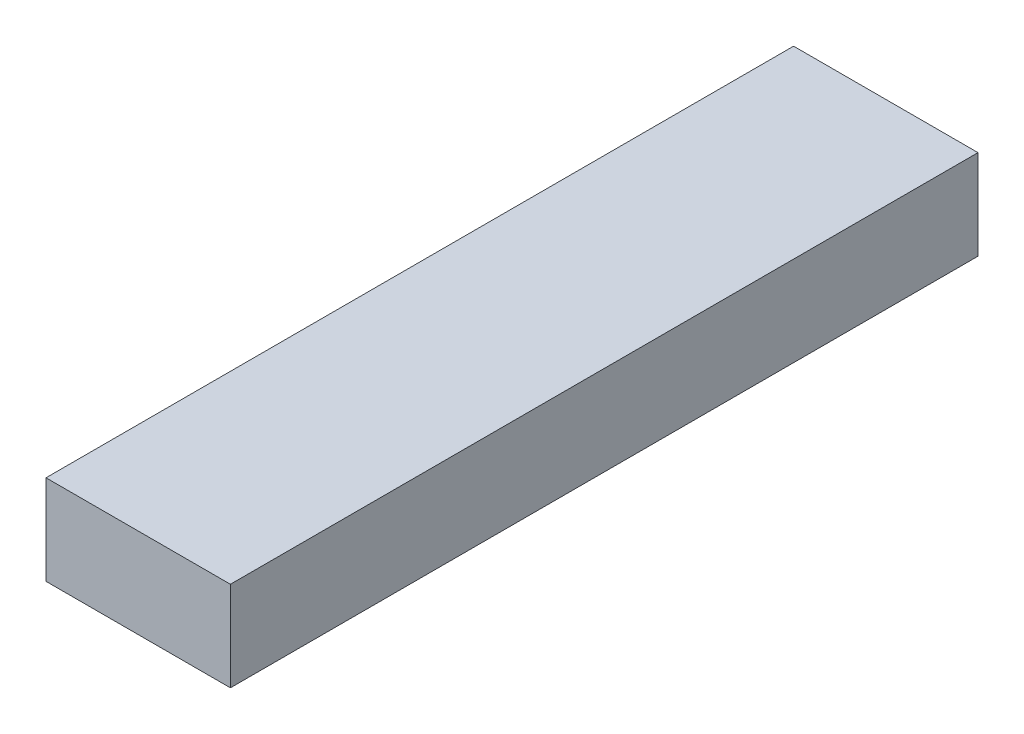
from build123d import *

# Parameters (mm, degrees)
SKETCH1_W           = 3.7
SKETCH1_H           = 1.8
BOSS_EXTRUDE1_DEPTH = 15


with BuildPart() as part:
    # Sketch1 → Boss-Extrude1 (new body)
    with BuildSketch(Plane.XY):
        Rectangle(SKETCH1_W, SKETCH1_H)
    extrude(amount=BOSS_EXTRUDE1_DEPTH)


solid = part.part
